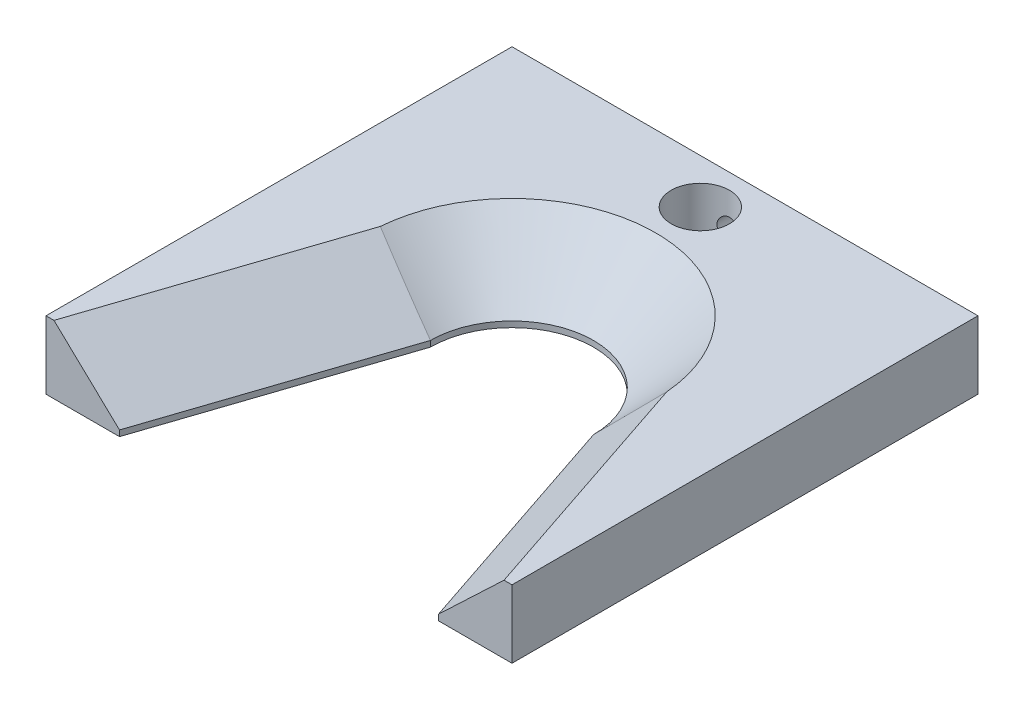
from build123d import *

# Parameters (mm, degrees)
BOSS_EXTRUDE1_DEPTH           = 11.1125
CHAMFER1_SIZE                 = 10.16
TAP_DRILL_FOR_8_32_TAP1_D     = 3.4544
TAP_DRILL_FOR_8_32_TAP1_DEPTH = 12.7
TAP_DRILL_FOR_8_32_TAP1_TIP   = 1.037806461
SKETCH27_R                    = 4.7625
CUT_EXTRUDE1_DEPTH            = 12.1125


with BuildPart() as part:
    # Sketch1 → Boss-Extrude1 (new body)
    with BuildSketch(Plane(origin=(0, 0, 0), x_dir=(1, 0, 0), z_dir=(0, 1, 0))):
        with BuildLine():
            Line((-26.083081673, -38.1), (-13.335, 0))
            ThreePointArc((-13.335, 0), (0, 13.335), (13.335, 0))
            Line((13.335, 0), (26.083081673, -38.1))
            Line((26.083081673, -38.1), (38.1, -38.1))
            Line((38.1, -38.1), (38.1, 38.1))
            Line((38.1, 38.1), (-38.1, 38.1))
            Line((-38.1, 38.1), (-38.1, -38.1))
            Line((-38.1, -38.1), (-26.083081673, -38.1))
        make_face()
    extrude(amount=BOSS_EXTRUDE1_DEPTH)

    # Chamfer1
    chamfer1_edges = [part.edges().sort_by_distance(p)[0] for p in [
        (19.709040837, 11.1125, 19.05),
        (-19.709040837, 11.1125, 19.05),
        (0, 11.1125, -13.335),
    ]]
    chamfer(chamfer1_edges, length=CHAMFER1_SIZE)

    # Tap Drill for #8-32 Tap1
    with Locations(Plane(origin=(0, 5.55625, -38.1), x_dir=(-1, 0, 0), z_dir=(0, 0, -1))):
        with Locations((0, 0)):
            Hole(TAP_DRILL_FOR_8_32_TAP1_D / 2, depth=TAP_DRILL_FOR_8_32_TAP1_DEPTH)
            with Locations((0, 0, -(TAP_DRILL_FOR_8_32_TAP1_DEPTH + TAP_DRILL_FOR_8_32_TAP1_TIP / 2))):  # 118° drill point
                Cone(0, TAP_DRILL_FOR_8_32_TAP1_D / 2, TAP_DRILL_FOR_8_32_TAP1_TIP, mode=Mode.SUBTRACT)

    # Sketch27 → Cut-Extrude1 (cut, through all)
    with BuildSketch(Plane(origin=(0, 11.1125, 0), x_dir=(1, 0, 0), z_dir=(0, 1, 0))):
        with Locations((0, 30.7975)):
            Circle(SKETCH27_R)
    extrude(amount=-CUT_EXTRUDE1_DEPTH, mode=Mode.SUBTRACT)


solid = part.part
